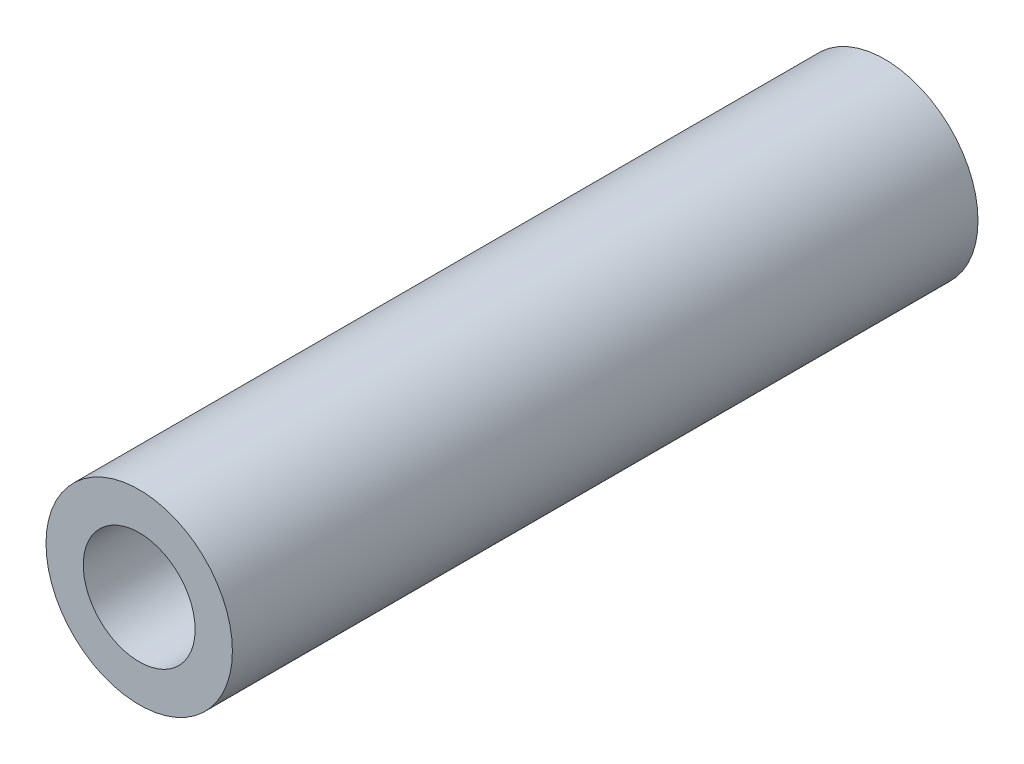
from build123d import *

# Parameters (mm, degrees)
SKETCH1_R           = 2.5
SKETCH1_R_2         = 1.5
BOSS_EXTRUDE1_DEPTH = 20


with BuildPart() as part:
    # Sketch1 → Boss-Extrude1 (new body)
    with BuildSketch(Plane.XY):
        Circle(SKETCH1_R)
        Circle(SKETCH1_R_2, mode=Mode.SUBTRACT)
    extrude(amount=BOSS_EXTRUDE1_DEPTH)


solid = part.part
